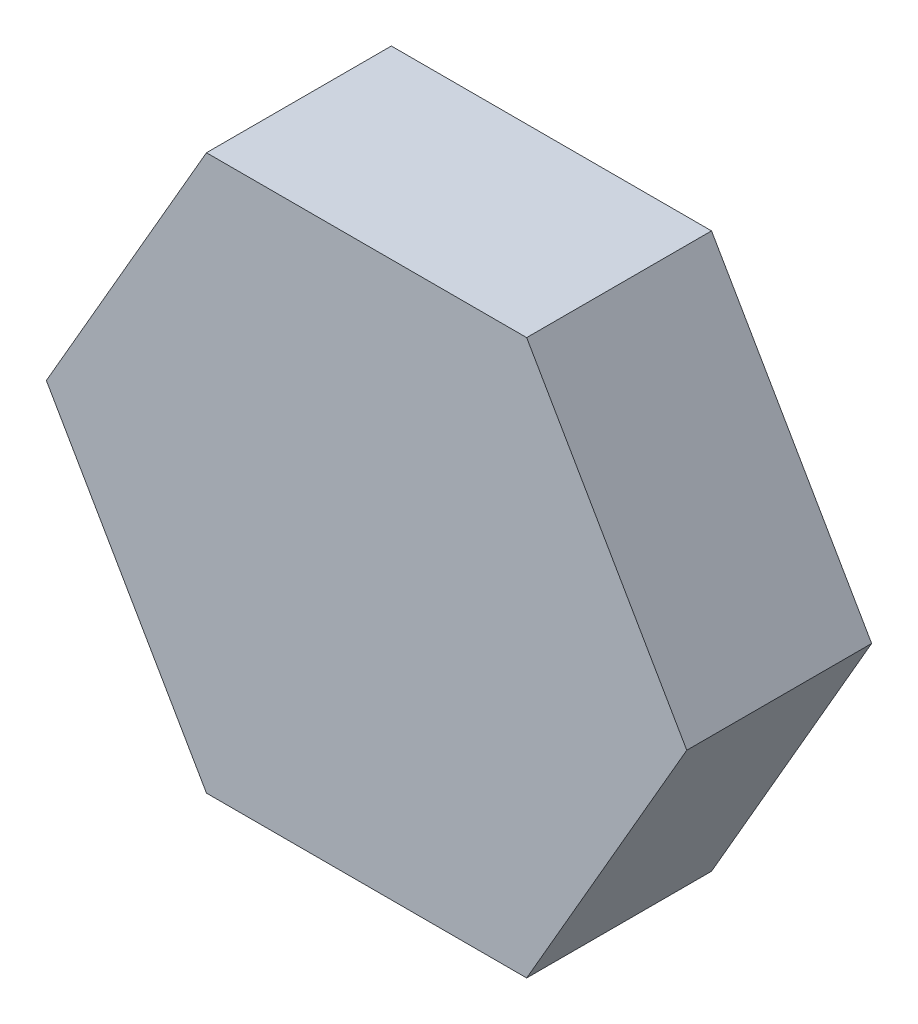
from build123d import *

# Parameters (mm, degrees)
BOSS_EXTRUDE1_DEPTH = 10


with BuildPart() as part:
    # Sketch1 → Boss-Extrude1 (new body)
    with BuildSketch(Plane.XY):
        Polygon((8.660254038, 15), (-8.660254038, 15), (-17.320508076, 0), (-8.660254038, -15), (8.660254038, -15), (17.320508076, 0), align=None)
    extrude(amount=BOSS_EXTRUDE1_DEPTH)


solid = part.part
